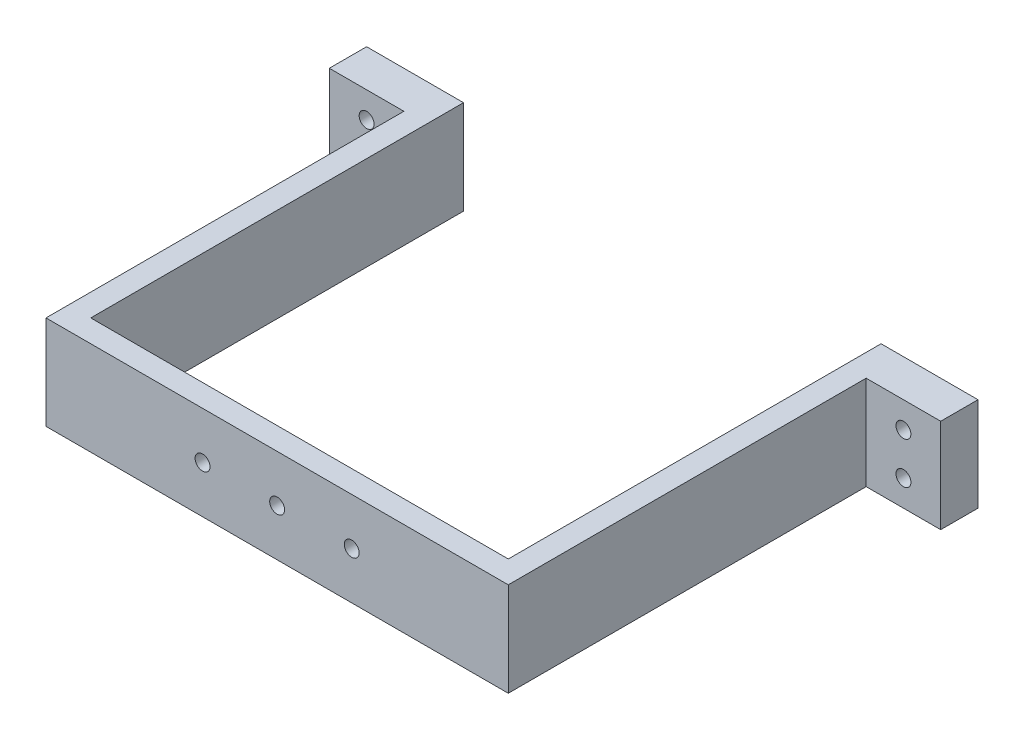
from build123d import *

# Parameters (mm, degrees)
SKETCH1_W           = 62
SKETCH1_H           = 12.6
SKETCH1_R           = 1
BOSS_EXTRUDE1_DEPTH = 3
SKETCH1_14_W        = 3
SKETCH1_14_H        = 12.6
BOSS_EXTRUDE2_DEPTH = 50
SKETCH6_W           = 10
SKETCH6_H           = 12.6
SKETCH6_R           = 1
BOSS_EXTRUDE5_DEPTH = 5


with BuildPart() as part:
    # Sketch1 → Boss-Extrude1 (new body)
    with BuildSketch(Plane.XY):
        with Locations((0, 14.697780108)):
            Rectangle(SKETCH1_W, SKETCH1_H)
        with Locations((0, 14.697780108)):
            Circle(SKETCH1_R, mode=Mode.SUBTRACT)
        with Locations((10, 14.697780108)):
            Circle(SKETCH1_R, mode=Mode.SUBTRACT)
        with Locations((-10, 14.697780108)):
            Circle(SKETCH1_R, mode=Mode.SUBTRACT)
    extrude(amount=BOSS_EXTRUDE1_DEPTH)

    # Sketch1_14 → Boss-Extrude2 (add)
    with BuildSketch(Plane.XY):
        with Locations((-29.5, 14.697780108)):
            Rectangle(SKETCH1_14_W, SKETCH1_14_H)
        with Locations((29.5, 14.697780108)):
            Rectangle(SKETCH1_14_W, SKETCH1_14_H)
    extrude(amount=-BOSS_EXTRUDE2_DEPTH)

    # Sketch6 → Boss-Extrude5 (add)
    # profile 1 of 2: a face of its own
    with BuildSketch(Plane(origin=(0, 0, -50), x_dir=(-1, 0, 0), z_dir=(0, 0, -1))):
        with Locations((36, 14.697780108)):
            Rectangle(SKETCH6_W, SKETCH6_H)
        with Locations((36, 11.897780108)):
            Circle(SKETCH6_R, mode=Mode.SUBTRACT)
        with Locations((36, 17.497780108)):
            Circle(SKETCH6_R, mode=Mode.SUBTRACT)
    # profile 2 of 2: a face of its own
    with BuildSketch(Plane(origin=(0, 0, -50), x_dir=(-1, 0, 0), z_dir=(0, 0, -1))):
        with Locations((-36, 14.697780108)):
            Rectangle(SKETCH6_W, SKETCH6_H)
        with Locations((-36, 11.897780108)):
            Circle(SKETCH6_R, mode=Mode.SUBTRACT)
        with Locations((-36, 17.497780108)):
            Circle(SKETCH6_R, mode=Mode.SUBTRACT)
    extrude(amount=-BOSS_EXTRUDE5_DEPTH)


solid = part.part
